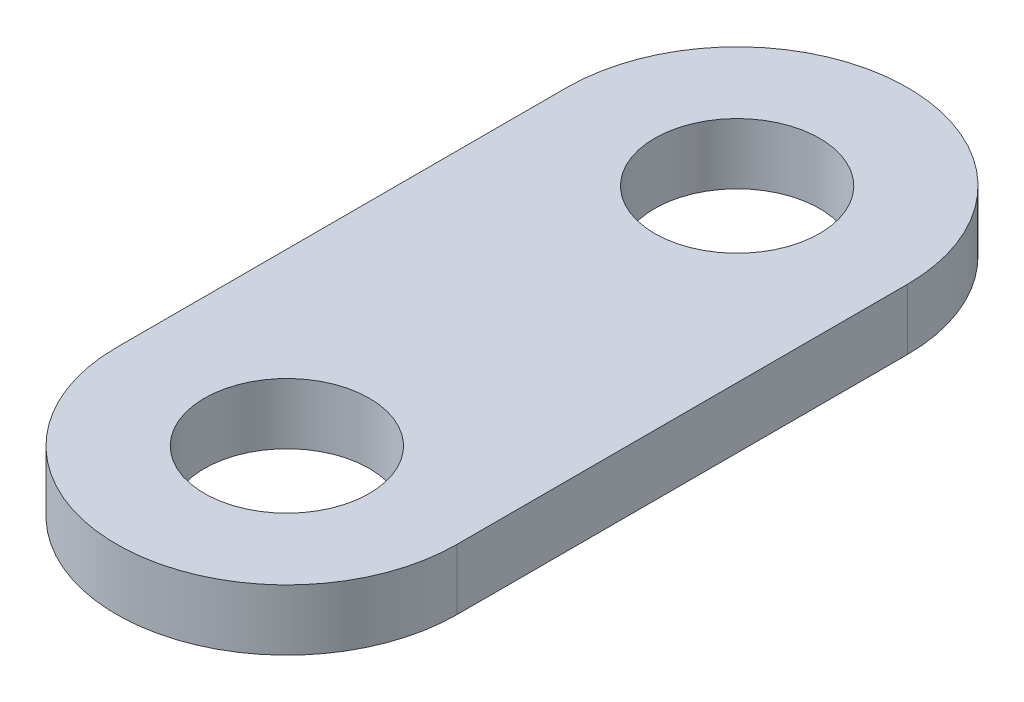
from build123d import *

# Parameters (mm, degrees)
SKETCH1_R           = 2.15265
BOSS_EXTRUDE1_DEPTH = 1.5875


with BuildPart() as part:
    # Sketch1 → Boss-Extrude1 (new body)
    with BuildSketch(Plane(origin=(0, 0, 0), x_dir=(1, 0, 0), z_dir=(0, 1, 0))):
        with BuildLine():
            Line((-4.445, 5.838159721), (-4.445, -5.909340279))
            ThreePointArc((-4.445, -5.909340279), (0, -10.354340279), (4.445, -5.909340279))
            Line((4.445, -5.909340279), (4.445, 5.838159721))
            ThreePointArc((4.445, 5.838159721), (0, 10.283159721), (-4.445, 5.838159721))
        make_face()
        with Locations((0, 5.838159721)):
            Circle(SKETCH1_R, mode=Mode.SUBTRACT)
        with Locations((0, -5.909340279)):
            Circle(SKETCH1_R, mode=Mode.SUBTRACT)
    extrude(amount=BOSS_EXTRUDE1_DEPTH)


solid = part.part
